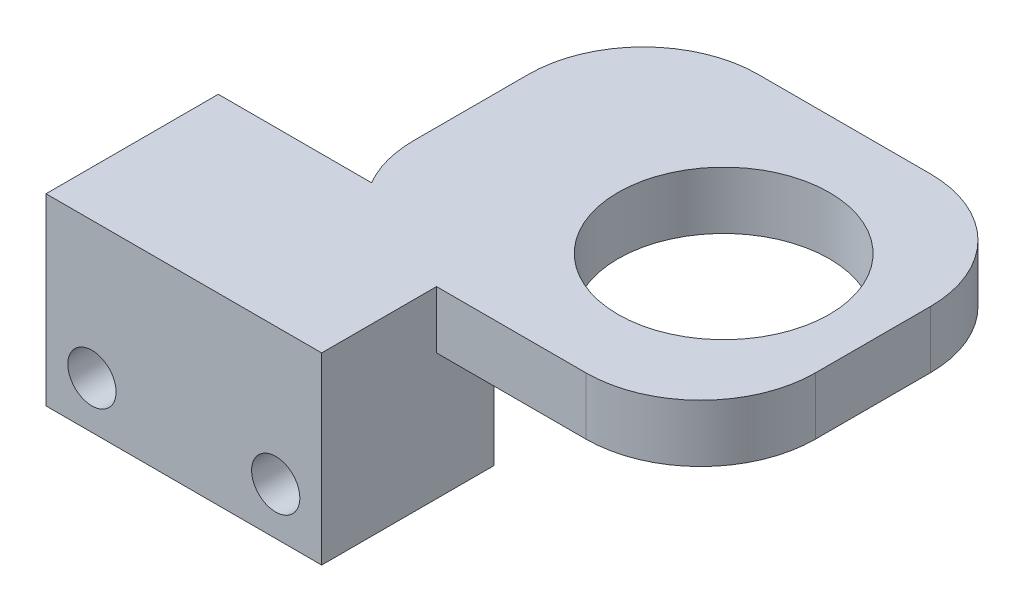
from build123d import *

# Parameters (mm, degrees)
SKIZZE1_W                       = 24
SKIZZE1_H                       = 16
SKIZZE1_R                       = 2.1
AUFSATZ_LINEAR_AUSTRAGEN2_DEPTH = 5
AUFSATZ_LINEAR_AUSTRAGEN6_DEPTH = 5
SKIZZE1_4_W                     = 24
SKIZZE1_4_H                     = 16
SKIZZE1_4_R                     = 2.1
AUFSATZ_LINEAR_AUSTRAGEN8_DEPTH = 15


with BuildPart() as part:
    # Skizze1 → Aufsatz-Linear austragen2 (new body)
    with BuildSketch(Plane.XY):
        with Locations((4.813396795, -3.212849162)):
            Rectangle(SKIZZE1_W, SKIZZE1_H)
        with Locations((-3.186603205, -7.112849162)):
            Circle(SKIZZE1_R, mode=Mode.SUBTRACT)
        with Locations((12.813396795, -7.112849162)):
            Circle(SKIZZE1_R, mode=Mode.SUBTRACT)
    extrude(amount=AUFSATZ_LINEAR_AUSTRAGEN2_DEPTH)

    # Skizze12 → Aufsatz-Linear austragen6 (add)
    with BuildSketch(Plane(origin=(0, 4.787150838, 0), x_dir=(1, 0, 0), z_dir=(0, 1, 0))):
        with BuildLine():
            Line((16.813396795, 0), (16.813396795, -5))
            Line((16.813396795, -5), (21.813396795, -5))
            Line((21.813396795, -5), (26.813396795, -5))
            Line((26.813396795, -5), (29.813396795, -5))
            ThreePointArc((29.813396795, -5), (36.884464607, -2.071067812), (39.813396795, 5))
            Line((39.813396795, 5), (39.813396795, 15))
            ThreePointArc((39.813396795, 15), (36.884464607, 22.071067812), (29.813396795, 25))
            Line((29.813396795, 25), (14.813396795, 25))
            ThreePointArc((14.813396795, 25), (7.742328983, 22.071067812), (4.813396795, 15))
            Line((4.813396795, 15), (4.813396795, 5))
            ThreePointArc((4.813396795, 5), (5.154138532, 2.411809549), (6.153142757, 0))
            Line((6.153142757, 0), (16.813396795, 0))
        make_face()
        with BuildLine():
            ThreePointArc((36.013396795, 10), (33.318779182, 3.494617613), (26.813396795, 0.8))
            ThreePointArc((26.813396795, 0.8), (20.308014408, 16.505382387), (36.013396795, 10))
        make_face(mode=Mode.SUBTRACT)
    extrude(amount=-AUFSATZ_LINEAR_AUSTRAGEN6_DEPTH)

    # Skizze1_4 → Aufsatz-Linear austragen8 (add)
    with BuildSketch(Plane.XY):
        with Locations((4.813396795, -3.212849162)):
            Rectangle(SKIZZE1_4_W, SKIZZE1_4_H)
        with Locations((-3.186603205, -7.112849162)):
            Circle(SKIZZE1_4_R, mode=Mode.SUBTRACT)
        with Locations((12.813396795, -7.112849162)):
            Circle(SKIZZE1_4_R, mode=Mode.SUBTRACT)
    extrude(amount=AUFSATZ_LINEAR_AUSTRAGEN8_DEPTH)


solid = part.part
